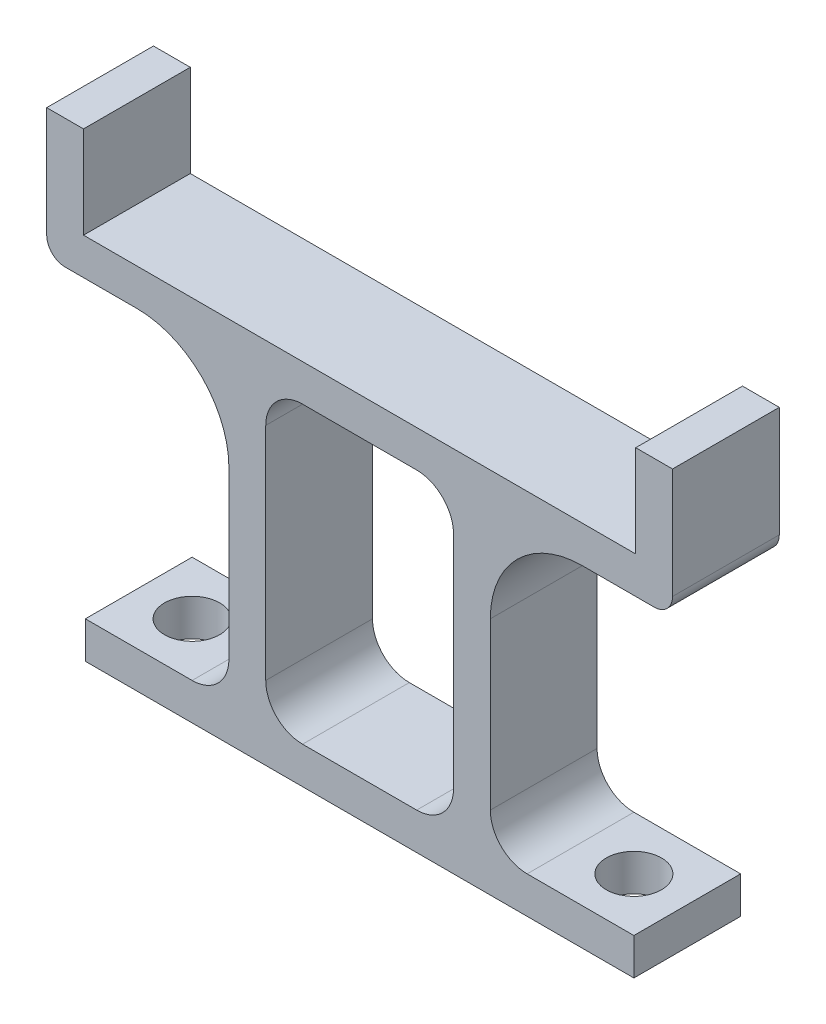
from build123d import *

# Parameters (mm, degrees)
SKETCH1_W           = 10.2
SKETCH1_H           = 16
BOSS_EXTRUDE1_DEPTH = 5.8
SKETCH2_R           = 1.5
CUT_EXTRUDE1_DEPTH  = 3
FILLET1_R           = 2


with BuildPart() as part:
    # Sketch1 → Boss-Extrude1 (new body)
    with BuildSketch(Plane.XY):
        with BuildLine():
            Line((-15, 25), (-15, 20))
            Line((-15, 20), (15, 20))
            Line((15, 20), (15, 25))
            Line((15, 25), (17, 25))
            Line((17, 25), (17, 19))
            ThreePointArc((17, 19), (16.707106781, 18.292893219), (16, 18))
            Line((16, 18), (12.1, 18))
            ThreePointArc((12.1, 18), (8.564466094, 16.535533906), (7.1, 13))
            Line((7.1, 13), (7.1, 4))
            ThreePointArc((7.1, 4), (7.685786438, 2.585786438), (9.1, 2))
            Line((9.1, 2), (14.9, 2))
            Line((14.9, 2), (14.9, 0))
            Line((14.9, 0), (-14.9, 0))
            Line((-14.9, 0), (-14.9, 2))
            Line((-14.9, 2), (-9.1, 2))
            ThreePointArc((-9.1, 2), (-7.685786438, 2.585786438), (-7.1, 4))
            Line((-7.1, 4), (-7.1, 13))
            ThreePointArc((-7.1, 13), (-8.564466094, 16.535533906), (-12.1, 18))
            Line((-12.1, 18), (-16, 18))
            ThreePointArc((-16, 18), (-16.707106781, 18.292893219), (-17, 19))
            Line((-17, 19), (-17, 25))
            Line((-17, 25), (-15, 25))
        make_face()
        with Locations((0, 10)):
            Rectangle(SKETCH1_W, SKETCH1_H, mode=Mode.SUBTRACT)
    extrude(amount=BOSS_EXTRUDE1_DEPTH)

    # Sketch2 → Cut-Extrude1 (cut, through all)
    with BuildSketch(Plane(origin=(0, 2, 0), x_dir=(1, 0, 0), z_dir=(0, 1, 0))):
        with Locations((-12, -2.9)):
            Circle(SKETCH2_R)
        with Locations((12, -2.9)):
            Circle(SKETCH2_R)
    extrude(amount=-CUT_EXTRUDE1_DEPTH, mode=Mode.SUBTRACT)

    # Fillet1
    fillet1_edges = [part.edges().sort_by_distance(p)[0] for p in [
        (-5.1, 18, 2.9),
        (-5.1, 2, 2.9),
        (5.1, 2, 2.9),
        (5.1, 18, 2.9),
    ]]
    fillet(fillet1_edges, radius=FILLET1_R)


solid = part.part
